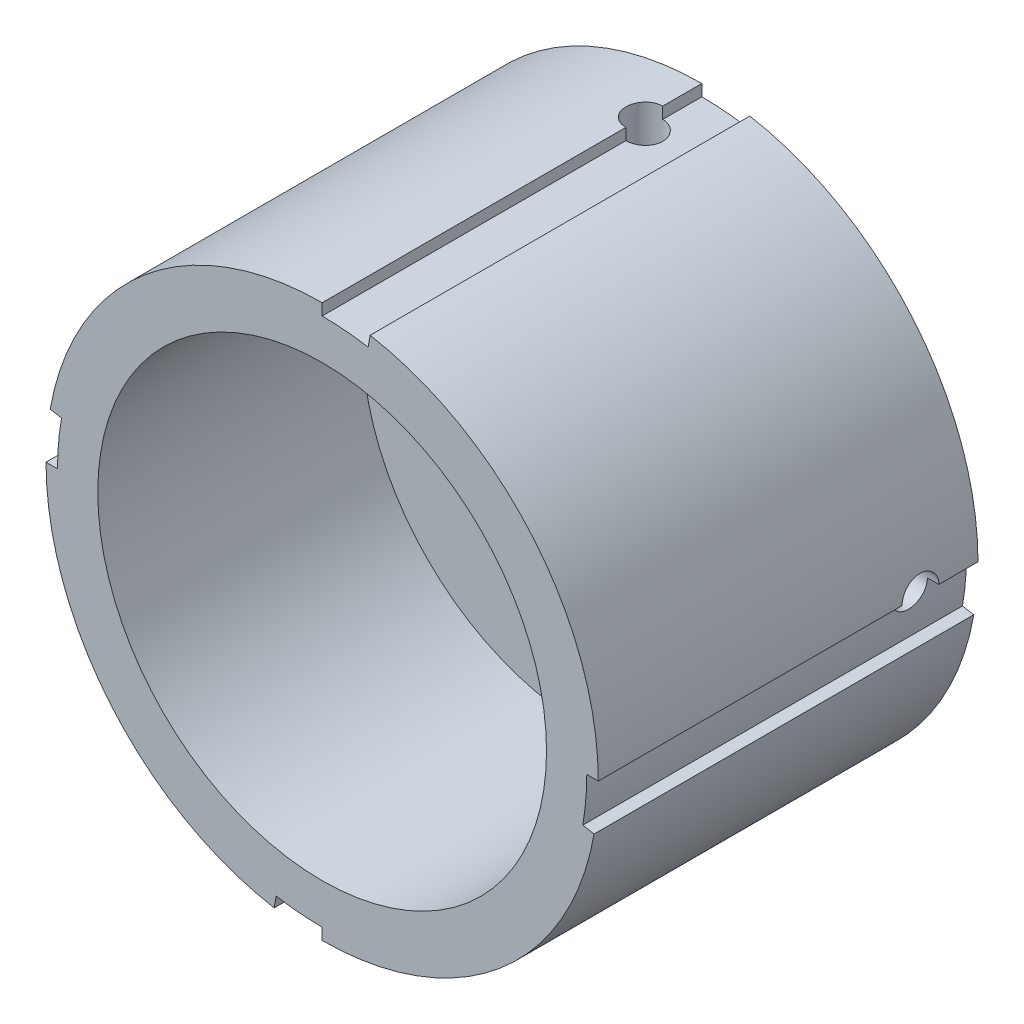
from build123d import *

# Parameters (mm, degrees)
SALIENTE_EXTRUIR1_DEPTH = 16.5
CROQUIS2_R              = 19.5
CORTAR_EXTRUIR1_DEPTH   = 23
CORTAR_EXTRUIR2_DEPTH   = 23
CROQUIS4_R              = 1.6
CORTAR_EXTRUIR3_DEPTH   = 36.5
CROQUIS5_R              = 1.6
CORTAR_EXTRUIR4_DEPTH   = 141.5
CROQUIS6_W              = 5.5
CROQUIS6_H              = 2.4
CROQUIS6_W_2            = 2.4
CROQUIS6_H_2            = 5.5
CORTAR_EXTRUIR5_DEPTH   = 283


with BuildPart() as part:
    # Croquis1 → Saliente-Extruir1 (new body, symmetric)
    with BuildSketch(Plane.XY):
        with BuildLine():
            Line((0, 24), (0, 23))
            ThreePointArc((0, 23), (2.004582083, 22.912478056), (3.993908086, 22.650578319))
            Line((3.993908086, 22.650578319), (4.167556264, 23.635386072))
            ThreePointArc((4.167556264, 23.635386072), (18.385066635, 15.426902632), (24, 0))
            Line((24, 0), (23, 0))
            ThreePointArc((23, 0), (22.912478056, -2.004582083), (22.650578319, -3.993908086))
            Line((22.650578319, -3.993908086), (23.635386072, -4.167556264))
            ThreePointArc((23.635386072, -4.167556264), (15.426902632, -18.385066635), (0, -24))
            Line((0, -24), (0, -23))
            ThreePointArc((0, -23), (-2.004582083, -22.912478056), (-3.993908086, -22.650578319))
            Line((-3.993908086, -22.650578319), (-4.167556264, -23.635386072))
            ThreePointArc((-4.167556264, -23.635386072), (-18.385066635, -15.426902632), (-24, 0))
            Line((-24, 0), (-23, 0))
            ThreePointArc((-23, 0), (-22.912478056, 2.004582083), (-22.650578319, 3.993908086))
            Line((-22.650578319, 3.993908086), (-23.635386072, 4.167556264))
            ThreePointArc((-23.635386072, 4.167556264), (-15.426902632, 18.385066635), (0, 24))
        make_face()
    extrude(amount=SALIENTE_EXTRUIR1_DEPTH, both=True)

    # Croquis2 → Cortar-Extruir1 (cut)
    with BuildSketch(Plane.XY.offset(16.5)):
        Circle(CROQUIS2_R)
    extrude(amount=-CORTAR_EXTRUIR1_DEPTH, mode=Mode.SUBTRACT)

    # Croquis3 → Cortar-Extruir2 (cut)
    with BuildSketch(Plane(origin=(0, 0, -16.5), x_dir=(-1, 0, 0), z_dir=(0, 0, -1))):
        with BuildLine():
            Line((1.030776406, 2), (-1.030776406, 2))
            ThreePointArc((-1.030776406, 2), (-1.17116461, -1.92116461), (2.25, 0))
            ThreePointArc((2.25, 0), (1.92116461, 1.17116461), (1.030776406, 2))
        make_face()
    extrude(amount=-CORTAR_EXTRUIR2_DEPTH, mode=Mode.SUBTRACT)

    # Croquis4 → Cortar-Extruir3 (cut, symmetric)
    with BuildSketch(Plane(origin=(0, 0, 0), x_dir=(1, 0, 0), z_dir=(0, 1, 0))):
        with Locations((0, 11.5)):
            Circle(CROQUIS4_R)
    extrude(amount=CORTAR_EXTRUIR3_DEPTH, both=True, mode=Mode.SUBTRACT)

    # Croquis5 → Cortar-Extruir4 (cut, symmetric)
    with BuildSketch(Plane(origin=(0, 0, 0), x_dir=(0, 0, -1), z_dir=(1, 0, 0))):
        with Locations((11.5, 0)):
            Circle(CROQUIS5_R)
    extrude(amount=CORTAR_EXTRUIR4_DEPTH, both=True, mode=Mode.SUBTRACT)

    # Croquis6 → Cortar-Extruir5 (cut)
    with BuildSketch(Plane(origin=(0, 0, -16.5), x_dir=(-1, 0, 0), z_dir=(0, 0, -1))):
        with Locations((0, 8.2)):
            Rectangle(CROQUIS6_W, CROQUIS6_H)
        with Locations((9.2, 0)):
            Rectangle(CROQUIS6_W_2, CROQUIS6_H_2)
    extrude(amount=-CORTAR_EXTRUIR5_DEPTH, mode=Mode.SUBTRACT)


solid = part.part
